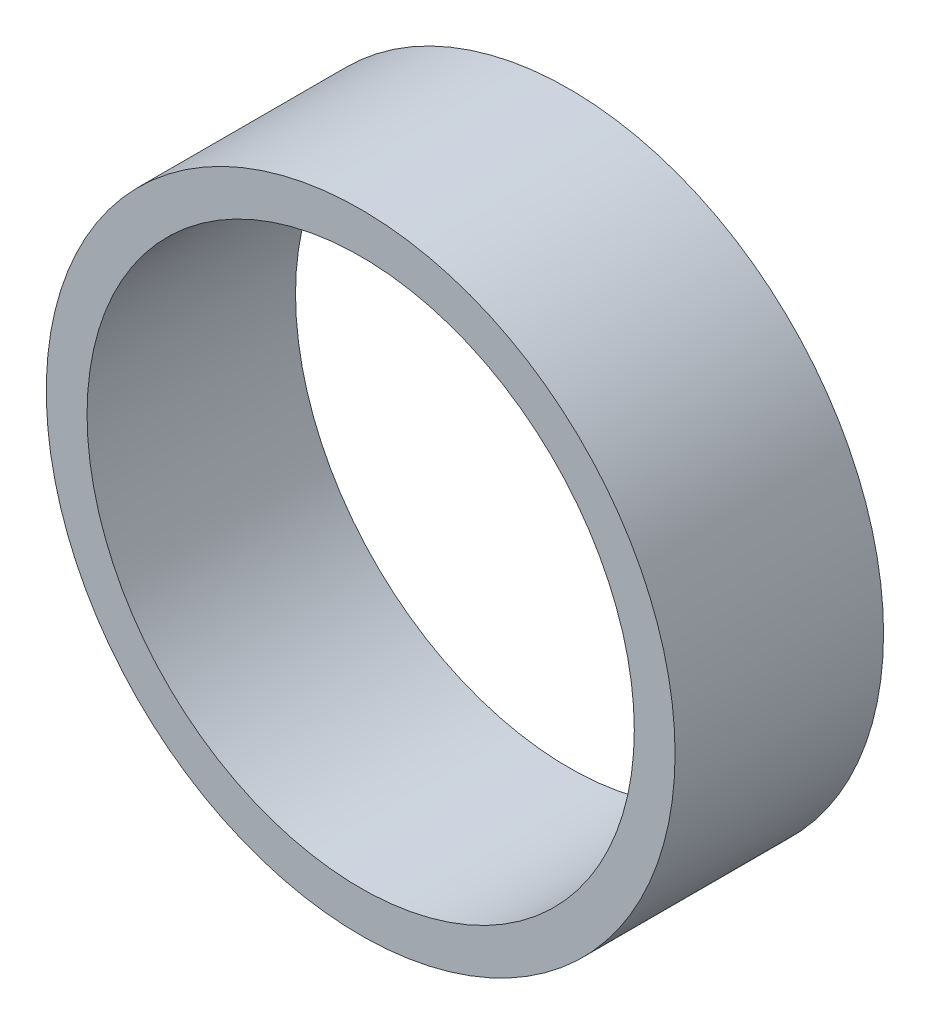
from build123d import *

# Parameters (mm, degrees)
SKETCH1_R           = 30.1625
SKETCH1_R_2         = 26.2509
EXTRUDE_THIN1_DEPTH = 10


with BuildPart() as part:
    # Sketch1 → Extrude-Thin1 (new body, symmetric)
    with BuildSketch(Plane.XY):
        Circle(SKETCH1_R)
        Circle(SKETCH1_R_2, mode=Mode.SUBTRACT)
    extrude(amount=EXTRUDE_THIN1_DEPTH, both=True)


solid = part.part
